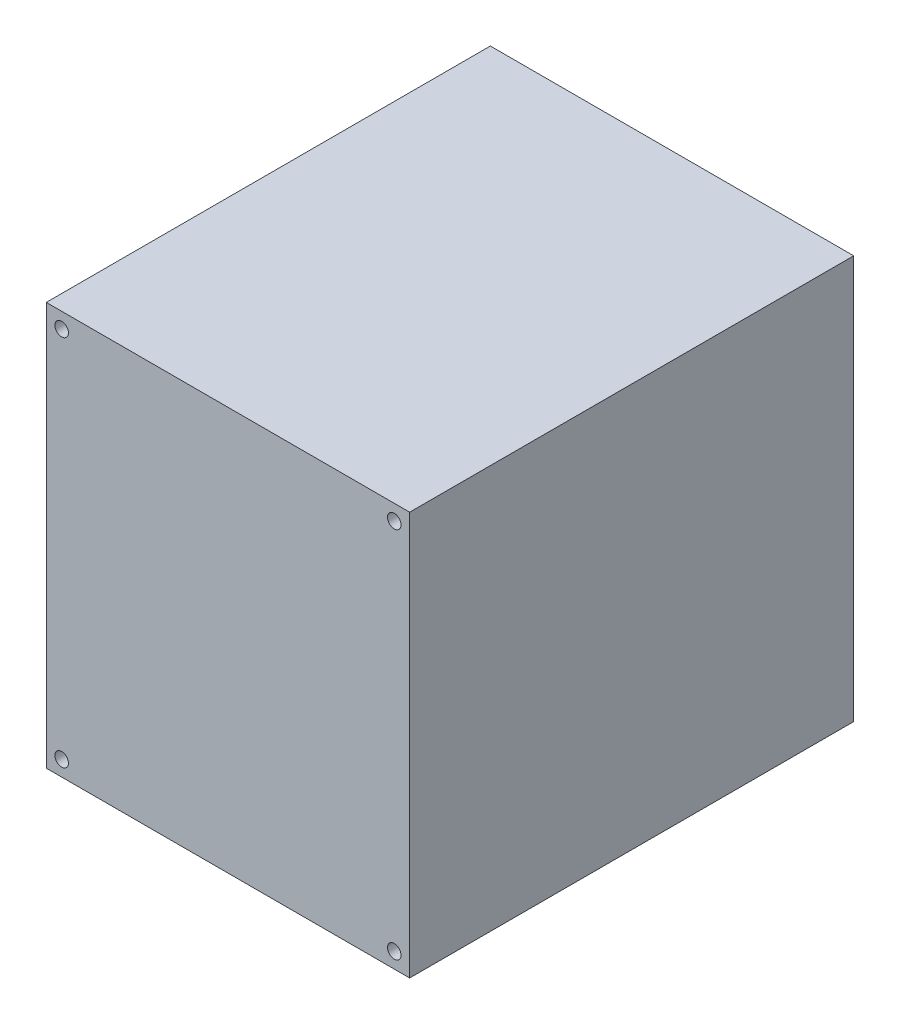
from build123d import *

# Parameters (mm, degrees)
SKETCH1_W           = 118
SKETCH1_H           = 131
BOSS_EXTRUDE1_DEPTH = 144.2
SKETCH2_R           = 2.2
CUT_EXTRUDE1_DEPTH  = 145.2


with BuildPart() as part:
    # Sketch1 → Boss-Extrude1 (new body)
    with BuildSketch(Plane.XY):
        Rectangle(SKETCH1_W, SKETCH1_H)
    extrude(amount=BOSS_EXTRUDE1_DEPTH)

    # Sketch2 → Cut-Extrude1 (cut, through all)
    with BuildSketch(Plane(origin=(0, 0, 0), x_dir=(-1, 0, 0), z_dir=(0, 0, -1))):
        with Locations((-54, 60.5)):
            Circle(SKETCH2_R)
        with Locations((54, 60.5)):
            Circle(SKETCH2_R)
        with Locations((54, -60.5)):
            Circle(SKETCH2_R)
        with Locations((-54, -60.5)):
            Circle(SKETCH2_R)
    extrude(amount=-CUT_EXTRUDE1_DEPTH, mode=Mode.SUBTRACT)


solid = part.part
